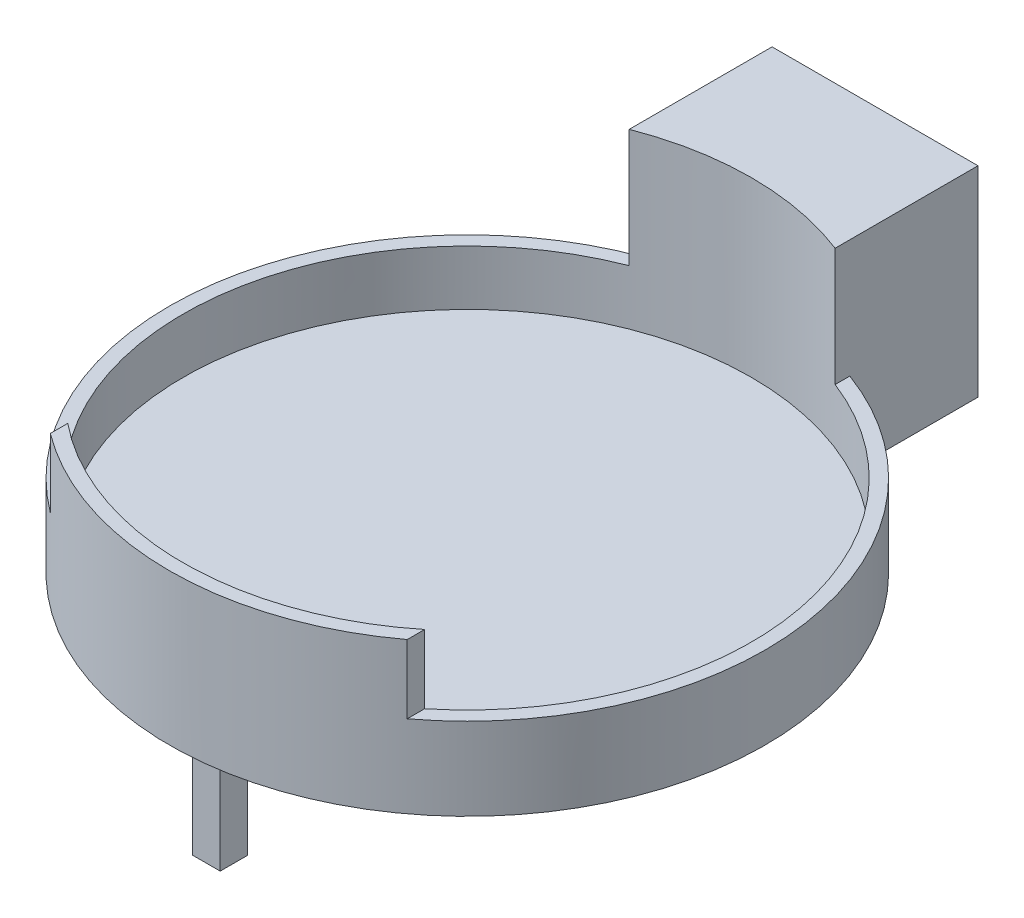
from build123d import *

# Parameters (mm, degrees)
SKETCH1_R               = 10.85
BOSS_EXTRUDE1_DEPTH     = 1
SKETCH2_W               = 1
SKETCH2_H               = 1
BOSS_EXTRUDE2_DEPTH     = 4.4
CIRPATTERN1_COUNT       = 2
SKETCH3_R               = 10.85
SKETCH3_R_2             = 10.35
BOSS_EXTRUDE3_DEPTH     = 6.3
CUT_EXTRUDE1_DEPTH      = 1.8
CUT_EXTRUDE4_DEPTH      = 2.8
CUT_EXTRUDE4_DEPTH_BACK = 2.5
BOSS_EXTRUDE4_DEPTH     = 7.3


with BuildPart() as part:
    # Sketch1 → Boss-Extrude1 (new body)
    with BuildSketch(Plane(origin=(0, 0, 0), x_dir=(1, 0, 0), z_dir=(0, 1, 0))):
        Circle(SKETCH1_R)
    extrude(amount=BOSS_EXTRUDE1_DEPTH)

    # Sketch2 → Boss-Extrude2 (add)
    with BuildSketch(Plane.XZ):
        with Locations((0, 9)):
            Rectangle(SKETCH2_W, SKETCH2_H)
    boss_extrude2 = extrude(amount=BOSS_EXTRUDE2_DEPTH)

    # CirPattern1: Boss-Extrude2 ×2 about axis
    cirpattern1_axis = Axis((0, 0, 0), (0, 1, 0))
    for i in range(1, CIRPATTERN1_COUNT):
        add(boss_extrude2.rotate(cirpattern1_axis, i * 360 / CIRPATTERN1_COUNT))

    # Sketch3 → Boss-Extrude3 (add)
    with BuildSketch(Plane(origin=(0, 1, 0), x_dir=(1, 0, 0), z_dir=(0, 1, 0))):
        Circle(SKETCH3_R)
        Circle(SKETCH3_R_2, mode=Mode.SUBTRACT)
    extrude(amount=BOSS_EXTRUDE3_DEPTH)

    # Sketch4 → Cut-Extrude1 (cut)
    with BuildSketch(Plane(origin=(0, 7.3, 0), x_dir=(1, 0, 0), z_dir=(0, 1, 0))):
        with BuildLine():
            Line((-3.75, 9.646761114), (-3.75, 10.181355509))
            ThreePointArc((-3.75, 10.181355509), (0, -10.85), (3.75, 10.181355509))
            Line((3.75, 10.181355509), (3.75, 9.646761114))
            ThreePointArc((3.75, 9.646761114), (0, -10.35), (-3.75, 9.646761114))
        make_face()
    extrude(amount=-CUT_EXTRUDE1_DEPTH, mode=Mode.SUBTRACT)

    # Sketch7 → Cut-Extrude4 (cut, two sides)
    with BuildSketch(Plane(origin=(0, 5.5, 0), x_dir=(1, 0, 0), z_dir=(0, 1, 0))) as cut_extrude4_sk:
        with BuildLine():
            Line((-6.5, -8.687491007), (-6.5, -8.054346653))
            ThreePointArc((-6.5, -8.054346653), (-10.227312895, 1.58888985), (-3.75, 9.646761114))
            Line((-3.75, 9.646761114), (-3.75, 10.181355509))
            ThreePointArc((-3.75, 10.181355509), (-10.736571483, 1.56477883), (-6.5, -8.687491007))
        make_face()
        with BuildLine():
            Line((6.5, -8.687491007), (6.5, -8.054346653))
            ThreePointArc((6.5, -8.054346653), (10.227312895, 1.58888985), (3.75, 9.646761114))
            Line((3.75, 9.646761114), (3.75, 10.181355509))
            ThreePointArc((3.75, 10.181355509), (10.736571483, 1.56477883), (6.5, -8.687491007))
        make_face()
    extrude(amount=CUT_EXTRUDE4_DEPTH, mode=Mode.SUBTRACT)
    extrude(cut_extrude4_sk.sketch, amount=-CUT_EXTRUDE4_DEPTH_BACK, mode=Mode.SUBTRACT)

    # Sketch8 → Boss-Extrude4 (add)
    with BuildSketch(Plane.XZ):
        with BuildLine():
            Line((-3.75, -10.181355509), (-3.75, -14.85))
            Line((-3.75, -14.85), (3.75, -14.85))
            Line((3.75, -14.85), (3.75, -10.181355509))
            ThreePointArc((3.75, -10.181355509), (0, -10.85), (-3.75, -10.181355509))
        make_face()
    extrude(amount=-BOSS_EXTRUDE4_DEPTH)


solid = part.part
